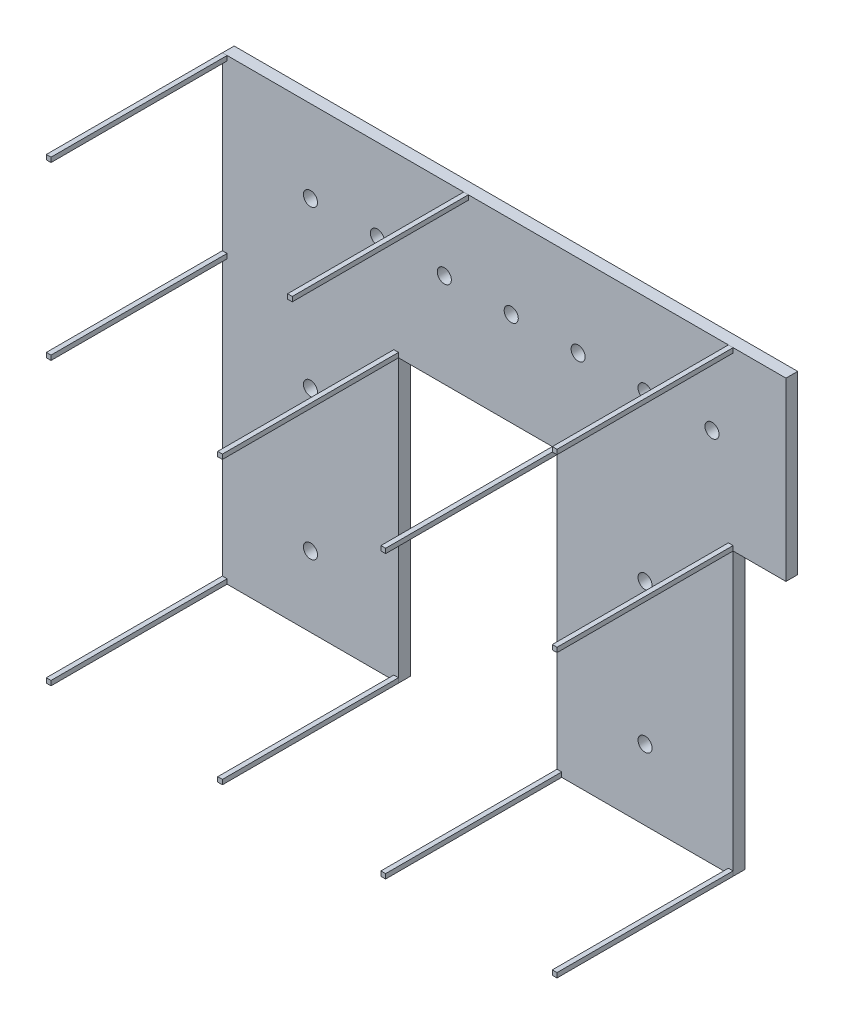
from build123d import *

# Parameters (mm, degrees)
SKETCH1_R              = 60
BOSS_EXTRUDE1_DEPTH    = 100
SKETCH2_W              = 40
SKETCH2_H              = 40
BOSS_EXTRUDE2_DEPTH    = 1500
BOSS_EXTRUDE2_2_DEPTH  = 1500
BOSS_EXTRUDE2_3_DEPTH  = 1500
BOSS_EXTRUDE2_4_DEPTH  = 1500
BOSS_EXTRUDE2_5_DEPTH  = 1500
BOSS_EXTRUDE2_6_DEPTH  = 1500
BOSS_EXTRUDE2_7_DEPTH  = 1500
BOSS_EXTRUDE2_8_DEPTH  = 1500
BOSS_EXTRUDE2_9_DEPTH  = 1500
BOSS_EXTRUDE2_10_DEPTH = 1500
BOSS_EXTRUDE2_11_DEPTH = 1500


with BuildPart() as part:
    # Sketch1 → Boss-Extrude1 (new body)
    with BuildSketch(Plane.XY):
        Polygon((0, 0), (0, 3900), (4800, 3900), (4800, 2400), (4350, 2400), (4350, 0), (2850, 0), (2850, 2400), (1500, 2400), (1500, 0), align=None)
        with Locations((750, 3200)):
            Circle(SKETCH1_R, mode=Mode.SUBTRACT)
        with Locations((1320, 3200)):
            Circle(SKETCH1_R, mode=Mode.SUBTRACT)
        with Locations((1890, 3200)):
            Circle(SKETCH1_R, mode=Mode.SUBTRACT)
        with Locations((2460, 3200)):
            Circle(SKETCH1_R, mode=Mode.SUBTRACT)
        with Locations((3030, 3200)):
            Circle(SKETCH1_R, mode=Mode.SUBTRACT)
        with Locations((3600, 3200)):
            Circle(SKETCH1_R, mode=Mode.SUBTRACT)
        with Locations((4170, 3200)):
            Circle(SKETCH1_R, mode=Mode.SUBTRACT)
        with Locations((750, 1800)):
            Circle(SKETCH1_R, mode=Mode.SUBTRACT)
        with Locations((750, 600)):
            Circle(SKETCH1_R, mode=Mode.SUBTRACT)
        with Locations((3600, 600)):
            Circle(SKETCH1_R, mode=Mode.SUBTRACT)
        with Locations((3600, 1800)):
            Circle(SKETCH1_R, mode=Mode.SUBTRACT)
    extrude(amount=BOSS_EXTRUDE1_DEPTH)


with BuildPart() as body_2:
    # Sketch2 → Boss-Extrude2 (new body)
    with BuildSketch(Plane.XY.offset(100)):
        with Locations((2870, 2420)):
            Rectangle(SKETCH2_W, SKETCH2_H)
    extrude(amount=BOSS_EXTRUDE2_DEPTH)


with BuildPart() as body_3:
    # Sketch2 → Boss-Extrude2 2 (new body)
    with BuildSketch(Plane.XY.offset(100)):
        with Locations((20, 3880)):
            Rectangle(SKETCH2_W, SKETCH2_H)
    extrude(amount=BOSS_EXTRUDE2_2_DEPTH)


with BuildPart() as body_4:
    # Sketch2 → Boss-Extrude2 3 (new body)
    with BuildSketch(Plane.XY.offset(100)):
        with Locations((20, 20)):
            Rectangle(SKETCH2_W, SKETCH2_H)
    extrude(amount=BOSS_EXTRUDE2_3_DEPTH)


with BuildPart() as body_5:
    # Sketch2 → Boss-Extrude2 4 (new body)
    with BuildSketch(Plane.XY.offset(100)):
        with Locations((1480, 20)):
            Rectangle(SKETCH2_W, SKETCH2_H)
    extrude(amount=BOSS_EXTRUDE2_4_DEPTH)


with BuildPart() as body_6:
    # Sketch2 → Boss-Extrude2 5 (new body)
    with BuildSketch(Plane.XY.offset(100)):
        with Locations((1480, 2420)):
            Rectangle(SKETCH2_W, SKETCH2_H)
    extrude(amount=BOSS_EXTRUDE2_5_DEPTH)


with BuildPart() as body_7:
    # Sketch2 → Boss-Extrude2 6 (new body)
    with BuildSketch(Plane.XY.offset(100)):
        with Locations((4330, 20)):
            Rectangle(SKETCH2_W, SKETCH2_H)
    extrude(amount=BOSS_EXTRUDE2_6_DEPTH)


with BuildPart() as body_8:
    # Sketch2 → Boss-Extrude2 7 (new body)
    with BuildSketch(Plane.XY.offset(100)):
        with Locations((2870, 20)):
            Rectangle(SKETCH2_W, SKETCH2_H)
    extrude(amount=BOSS_EXTRUDE2_7_DEPTH)


with BuildPart() as body_9:
    # Sketch2 → Boss-Extrude2 8 (new body)
    with BuildSketch(Plane.XY.offset(100)):
        with Locations((4330, 2420)):
            Rectangle(SKETCH2_W, SKETCH2_H)
    extrude(amount=BOSS_EXTRUDE2_8_DEPTH)


with BuildPart() as body_10:
    # Sketch2 → Boss-Extrude2 9 (new body)
    with BuildSketch(Plane.XY.offset(100)):
        with Locations((4330, 3880)):
            Rectangle(SKETCH2_W, SKETCH2_H)
    extrude(amount=BOSS_EXTRUDE2_9_DEPTH)


with BuildPart() as body_11:
    # Sketch2 → Boss-Extrude2 10 (new body)
    with BuildSketch(Plane.XY.offset(100)):
        with Locations((2075, 3880)):
            Rectangle(SKETCH2_W, SKETCH2_H)
    extrude(amount=BOSS_EXTRUDE2_10_DEPTH)


with BuildPart() as body_12:
    # Sketch2 → Boss-Extrude2 11 (new body)
    with BuildSketch(Plane.XY.offset(100)):
        with Locations((20, 2420)):
            Rectangle(SKETCH2_W, SKETCH2_H)
    extrude(amount=BOSS_EXTRUDE2_11_DEPTH)


solid = Compound([part.part, body_2.part, body_3.part, body_4.part, body_5.part, body_6.part, body_7.part, body_8.part, body_9.part, body_10.part, body_11.part, body_12.part])
